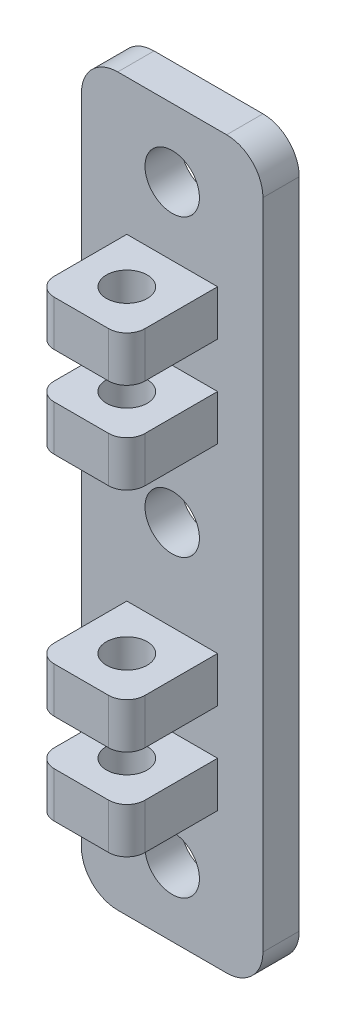
from build123d import *

# Parameters (mm, degrees)
ESQUISSE1_W             = 20
ESQUISSE1_H             = 80
BOSS_EXTRU_1_DEPTH      = 4
ESQUISSE2_W             = 10
ESQUISSE2_H             = 5
BOSS_EXTRU_2_DEPTH      = 10
ESQUISSE3_R             = 2.25
ENL_V_MAT_EXTRU_1_DEPTH = 66
CONG_1_R                = 2
CONG_2_R                = 4
ESQUISSE4_R             = 3
ENL_V_MAT_EXTRU_2_DEPTH = 5


with BuildPart() as part:
    # Esquisse1 → Boss.-Extru.1 (new body)
    with BuildSketch(Plane.XY):
        with Locations((-10, 40)):
            Rectangle(ESQUISSE1_W, ESQUISSE1_H)
    extrude(amount=BOSS_EXTRU_1_DEPTH)

    # Esquisse2 → Boss.-Extru.2 (add)
    with BuildSketch(Plane.XY.offset(4)):
        with Locations((-10, 62.5)):
            Rectangle(ESQUISSE2_W, ESQUISSE2_H)
        with Locations((-10, 52.5)):
            Rectangle(ESQUISSE2_W, ESQUISSE2_H)
        with Locations((-10, 27.5)):
            Rectangle(ESQUISSE2_W, ESQUISSE2_H)
        with Locations((-10, 17.5)):
            Rectangle(ESQUISSE2_W, ESQUISSE2_H)
    extrude(amount=BOSS_EXTRU_2_DEPTH)

    # Esquisse3 → Enlèv. mat.-Extru.1 (cut, through all)
    with BuildSketch(Plane.XZ.offset(-15)):
        with Locations(Location((-10, 9, 0), (0, 0, 270))):  # turned: the seam where the file's is
            Circle(ESQUISSE3_R)
    extrude(amount=-ENL_V_MAT_EXTRU_1_DEPTH, mode=Mode.SUBTRACT)

    # Congé1
    cong_1_edges = [part.edges().sort_by_distance(p)[0] for p in [
        (-15, 62.5, 14),
        (-5, 62.5, 14),
        (-15, 52.5, 14),
        (-5, 52.5, 14),
        (-15, 27.5, 14),
        (-5, 27.5, 14),
        (-15, 17.5, 14),
        (-5, 17.5, 14),
    ]]
    fillet(cong_1_edges, radius=CONG_1_R)

    # Congé2
    cong_2_edges = [part.edges().sort_by_distance(p)[0] for p in [
        (-20, 80, 2),
        (0, 80, 2),
        (0, 0, 2),
        (-20, 0, 2),
    ]]
    fillet(cong_2_edges, radius=CONG_2_R)

    # Esquisse4 → Enlèv. mat.-Extru.2 (cut, through all)
    with BuildSketch(Plane.XY.offset(4)):
        with Locations((-10, 7.5)):
            Circle(ESQUISSE4_R)
        with Locations((-10, 72.5)):
            Circle(ESQUISSE4_R)
        with Locations((-10, 40)):
            Circle(ESQUISSE4_R)
    extrude(amount=-ENL_V_MAT_EXTRU_2_DEPTH, mode=Mode.SUBTRACT)


solid = part.part
